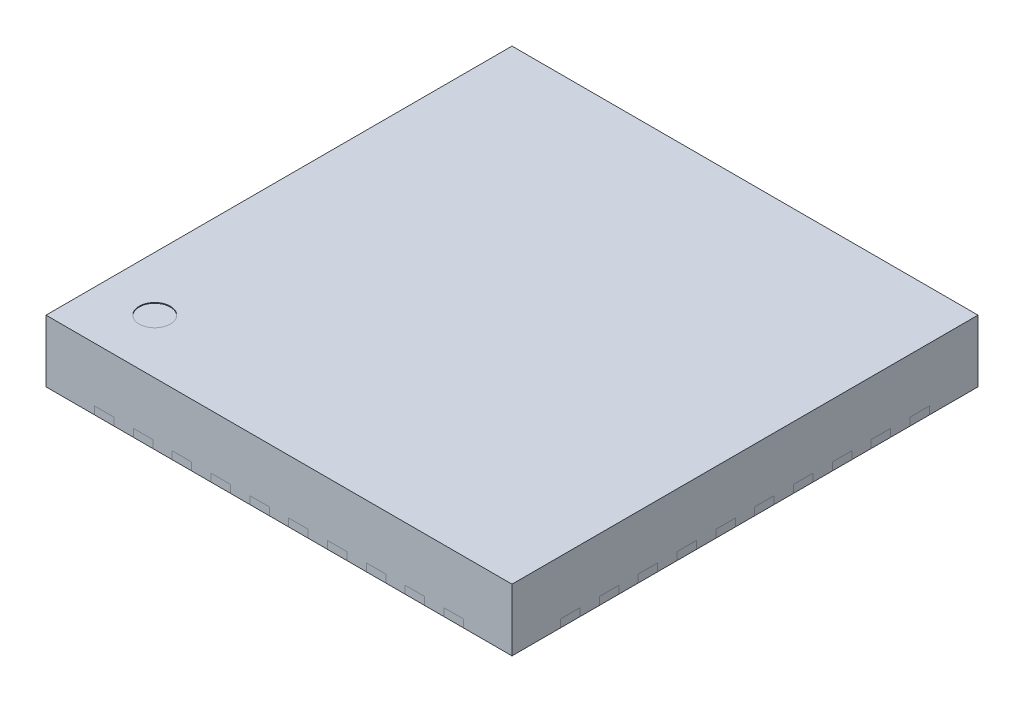
from build123d import *

# Parameters (mm, degrees)
SKETCH_1_W          = 6
SKETCH_1_H          = 6
EXTRUDE_1_DEPTH     = 0.8
SKETCH_2_W          = 0.25
SKETCH_2_H          = 0.4
SKETCH_2_W_2        = 0.4
SKETCH_2_H_2        = 0.25
CUT_EXTRUDE_2_DEPTH = 0.1
SKETCH_2_3_W        = 0.25
SKETCH_2_3_H        = 0.4
EXTRUDE_3_DEPTH     = 0.1
EXTRUDE_3_2_DEPTH   = 0.1
EXTRUDE_3_3_DEPTH   = 0.1
EXTRUDE_3_4_DEPTH   = 0.1
EXTRUDE_3_5_DEPTH   = 0.1
SKETCH_2_3_W_2      = 0.4
SKETCH_2_3_H_2      = 0.25
EXTRUDE_3_6_DEPTH   = 0.1
EXTRUDE_3_7_DEPTH   = 0.1
EXTRUDE_3_8_DEPTH   = 0.1
EXTRUDE_3_9_DEPTH   = 0.1
EXTRUDE_3_10_DEPTH  = 0.1
EXTRUDE_3_11_DEPTH  = 0.1
EXTRUDE_3_12_DEPTH  = 0.1
EXTRUDE_3_13_DEPTH  = 0.1
EXTRUDE_3_14_DEPTH  = 0.1
EXTRUDE_3_15_DEPTH  = 0.1
EXTRUDE_3_16_DEPTH  = 0.1
EXTRUDE_3_17_DEPTH  = 0.1
EXTRUDE_3_18_DEPTH  = 0.1
EXTRUDE_3_19_DEPTH  = 0.1
EXTRUDE_3_20_DEPTH  = 0.1
EXTRUDE_3_21_DEPTH  = 0.1
EXTRUDE_3_22_DEPTH  = 0.1
EXTRUDE_3_23_DEPTH  = 0.1
EXTRUDE_3_24_DEPTH  = 0.1
EXTRUDE_3_25_DEPTH  = 0.1
EXTRUDE_3_26_DEPTH  = 0.1
EXTRUDE_3_27_DEPTH  = 0.1
EXTRUDE_3_28_DEPTH  = 0.1
EXTRUDE_3_29_DEPTH  = 0.1
EXTRUDE_3_30_DEPTH  = 0.1
EXTRUDE_3_31_DEPTH  = 0.1
EXTRUDE_3_32_DEPTH  = 0.1
EXTRUDE_3_33_DEPTH  = 0.1
EXTRUDE_3_34_DEPTH  = 0.1
EXTRUDE_3_35_DEPTH  = 0.1
EXTRUDE_3_36_DEPTH  = 0.1
EXTRUDE_3_37_DEPTH  = 0.1
EXTRUDE_3_38_DEPTH  = 0.1
EXTRUDE_3_39_DEPTH  = 0.1
EXTRUDE_3_40_DEPTH  = 0.1
EXTRUDE_3_41_DEPTH  = 0.1
SKETCH_3_R          = 0.2
CUT_EXTRUDE_4_DEPTH = 0.01


with BuildPart() as part:
    # Эскиз1 → Вытянуть1 (new body)
    with BuildSketch(Plane(origin=(0, 0, 0), x_dir=(1, 0, 0), z_dir=(0, 1, 0))):
        Rectangle(SKETCH_1_W, SKETCH_1_H)
    extrude(amount=EXTRUDE_1_DEPTH)

    # Эскиз2 → Вытянуть2 (cut)
    with BuildSketch(Plane.XZ):
        with Locations((-0.25, 2.8)):
            Rectangle(SKETCH_2_W, SKETCH_2_H)
        with Locations((-0.75, 2.8)):
            Rectangle(SKETCH_2_W, SKETCH_2_H)
        with Locations((-1.25, 2.8)):
            Rectangle(SKETCH_2_W, SKETCH_2_H)
        with Locations((-1.75, 2.8)):
            Rectangle(SKETCH_2_W, SKETCH_2_H)
        with Locations((-2.25, 2.8)):
            Rectangle(SKETCH_2_W, SKETCH_2_H)
        with Locations((2.8, 0.25)):
            Rectangle(SKETCH_2_W_2, SKETCH_2_H_2)
        Polygon((-2.3, 2.05), (-2.05, 2.3), (2.3, 2.3), (2.3, -2.3), (-2.3, -2.3), align=None)
        with Locations((2.25, 2.8)):
            Rectangle(SKETCH_2_W, SKETCH_2_H)
        with Locations((1.75, 2.8)):
            Rectangle(SKETCH_2_W, SKETCH_2_H)
        with Locations((1.25, 2.8)):
            Rectangle(SKETCH_2_W, SKETCH_2_H)
        with Locations((0.75, 2.8)):
            Rectangle(SKETCH_2_W, SKETCH_2_H)
        with Locations((0.25, 2.8)):
            Rectangle(SKETCH_2_W, SKETCH_2_H)
        with Locations((2.8, 0.75)):
            Rectangle(SKETCH_2_W_2, SKETCH_2_H_2)
        with Locations((2.8, 1.25)):
            Rectangle(SKETCH_2_W_2, SKETCH_2_H_2)
        with Locations((2.8, 1.75)):
            Rectangle(SKETCH_2_W_2, SKETCH_2_H_2)
        with Locations((2.8, 2.25)):
            Rectangle(SKETCH_2_W_2, SKETCH_2_H_2)
        with Locations((2.8, -2.25)):
            Rectangle(SKETCH_2_W_2, SKETCH_2_H_2)
        with Locations((2.8, -1.75)):
            Rectangle(SKETCH_2_W_2, SKETCH_2_H_2)
        with Locations((2.8, -1.25)):
            Rectangle(SKETCH_2_W_2, SKETCH_2_H_2)
        with Locations((2.8, -0.75)):
            Rectangle(SKETCH_2_W_2, SKETCH_2_H_2)
        with Locations((2.8, -0.25)):
            Rectangle(SKETCH_2_W_2, SKETCH_2_H_2)
        with Locations((0.25, -2.8)):
            Rectangle(SKETCH_2_W, SKETCH_2_H)
        with Locations((0.75, -2.8)):
            Rectangle(SKETCH_2_W, SKETCH_2_H)
        with Locations((1.25, -2.8)):
            Rectangle(SKETCH_2_W, SKETCH_2_H)
        with Locations((1.75, -2.8)):
            Rectangle(SKETCH_2_W, SKETCH_2_H)
        with Locations((2.25, -2.8)):
            Rectangle(SKETCH_2_W, SKETCH_2_H)
        with Locations((-2.25, -2.8)):
            Rectangle(SKETCH_2_W, SKETCH_2_H)
        with Locations((-1.75, -2.8)):
            Rectangle(SKETCH_2_W, SKETCH_2_H)
        with Locations((-1.25, -2.8)):
            Rectangle(SKETCH_2_W, SKETCH_2_H)
        with Locations((-0.75, -2.8)):
            Rectangle(SKETCH_2_W, SKETCH_2_H)
        with Locations((-0.25, -2.8)):
            Rectangle(SKETCH_2_W, SKETCH_2_H)
        with Locations((-2.8, -0.25)):
            Rectangle(SKETCH_2_W_2, SKETCH_2_H_2)
        with Locations((-2.8, -0.75)):
            Rectangle(SKETCH_2_W_2, SKETCH_2_H_2)
        with Locations((-2.8, -1.25)):
            Rectangle(SKETCH_2_W_2, SKETCH_2_H_2)
        with Locations((-2.8, -1.75)):
            Rectangle(SKETCH_2_W_2, SKETCH_2_H_2)
        with Locations((-2.8, -2.25)):
            Rectangle(SKETCH_2_W_2, SKETCH_2_H_2)
        with Locations((-2.8, 2.25)):
            Rectangle(SKETCH_2_W_2, SKETCH_2_H_2)
        with Locations((-2.8, 1.75)):
            Rectangle(SKETCH_2_W_2, SKETCH_2_H_2)
        with Locations((-2.8, 1.25)):
            Rectangle(SKETCH_2_W_2, SKETCH_2_H_2)
        with Locations((-2.8, 0.75)):
            Rectangle(SKETCH_2_W_2, SKETCH_2_H_2)
        with Locations((-2.8, 0.25)):
            Rectangle(SKETCH_2_W_2, SKETCH_2_H_2)
    extrude(amount=-CUT_EXTRUDE_2_DEPTH, mode=Mode.SUBTRACT)

    # Эскиз3 → Вытянуть4 (cut)
    with BuildSketch(Plane(origin=(0, 0.8, 0), x_dir=(1, 0, 0), z_dir=(0, 1, 0))):
        with Locations((-2.3, -2.3)):
            Circle(SKETCH_3_R)
    extrude(amount=-CUT_EXTRUDE_4_DEPTH, mode=Mode.SUBTRACT)


with BuildPart() as body_2:
    # Эскиз2<3> → Вытянуть3 (new body)
    with BuildSketch(Plane.XZ):
        with Locations((-0.25, 2.8)):
            Rectangle(SKETCH_2_3_W, SKETCH_2_3_H)
    extrude(amount=-EXTRUDE_3_DEPTH)


with BuildPart() as body_3:
    # Эскиз2<3> → Extrude 3 2 (new body)
    with BuildSketch(Plane.XZ):
        with Locations((-0.75, 2.8)):
            Rectangle(SKETCH_2_3_W, SKETCH_2_3_H)
    extrude(amount=-EXTRUDE_3_2_DEPTH)


with BuildPart() as body_4:
    # Эскиз2<3> → Extrude 3 3 (new body)
    with BuildSketch(Plane.XZ):
        with Locations((-1.25, 2.8)):
            Rectangle(SKETCH_2_3_W, SKETCH_2_3_H)
    extrude(amount=-EXTRUDE_3_3_DEPTH)


with BuildPart() as body_5:
    # Эскиз2<3> → Extrude 3 4 (new body)
    with BuildSketch(Plane.XZ):
        with Locations((-1.75, 2.8)):
            Rectangle(SKETCH_2_3_W, SKETCH_2_3_H)
    extrude(amount=-EXTRUDE_3_4_DEPTH)


with BuildPart() as body_6:
    # Эскиз2<3> → Extrude 3 5 (new body)
    with BuildSketch(Plane.XZ):
        with Locations((-2.25, 2.8)):
            Rectangle(SKETCH_2_3_W, SKETCH_2_3_H)
    extrude(amount=-EXTRUDE_3_5_DEPTH)


with BuildPart() as body_7:
    # Эскиз2<3> → Extrude 3 6 (new body)
    with BuildSketch(Plane.XZ):
        with Locations((2.8, 0.25)):
            Rectangle(SKETCH_2_3_W_2, SKETCH_2_3_H_2)
    extrude(amount=-EXTRUDE_3_6_DEPTH)


with BuildPart() as body_8:
    # Эскиз2<3> → Extrude 3 7 (new body)
    with BuildSketch(Plane.XZ):
        Polygon((-2.3, 2.05), (-2.05, 2.3), (2.3, 2.3), (2.3, -2.3), (-2.3, -2.3), align=None)
    extrude(amount=-EXTRUDE_3_7_DEPTH)


with BuildPart() as body_9:
    # Эскиз2<3> → Extrude 3 8 (new body)
    with BuildSketch(Plane.XZ):
        with Locations((2.25, 2.8)):
            Rectangle(SKETCH_2_3_W, SKETCH_2_3_H)
    extrude(amount=-EXTRUDE_3_8_DEPTH)


with BuildPart() as body_10:
    # Эскиз2<3> → Extrude 3 9 (new body)
    with BuildSketch(Plane.XZ):
        with Locations((1.75, 2.8)):
            Rectangle(SKETCH_2_3_W, SKETCH_2_3_H)
    extrude(amount=-EXTRUDE_3_9_DEPTH)


with BuildPart() as body_11:
    # Эскиз2<3> → Extrude 3 10 (new body)
    with BuildSketch(Plane.XZ):
        with Locations((1.25, 2.8)):
            Rectangle(SKETCH_2_3_W, SKETCH_2_3_H)
    extrude(amount=-EXTRUDE_3_10_DEPTH)


with BuildPart() as body_12:
    # Эскиз2<3> → Extrude 3 11 (new body)
    with BuildSketch(Plane.XZ):
        with Locations((0.75, 2.8)):
            Rectangle(SKETCH_2_3_W, SKETCH_2_3_H)
    extrude(amount=-EXTRUDE_3_11_DEPTH)


with BuildPart() as body_13:
    # Эскиз2<3> → Extrude 3 12 (new body)
    with BuildSketch(Plane.XZ):
        with Locations((0.25, 2.8)):
            Rectangle(SKETCH_2_3_W, SKETCH_2_3_H)
    extrude(amount=-EXTRUDE_3_12_DEPTH)


with BuildPart() as body_14:
    # Эскиз2<3> → Extrude 3 13 (new body)
    with BuildSketch(Plane.XZ):
        with Locations((2.8, 0.75)):
            Rectangle(SKETCH_2_3_W_2, SKETCH_2_3_H_2)
    extrude(amount=-EXTRUDE_3_13_DEPTH)


with BuildPart() as body_15:
    # Эскиз2<3> → Extrude 3 14 (new body)
    with BuildSketch(Plane.XZ):
        with Locations((2.8, 1.25)):
            Rectangle(SKETCH_2_3_W_2, SKETCH_2_3_H_2)
    extrude(amount=-EXTRUDE_3_14_DEPTH)


with BuildPart() as body_16:
    # Эскиз2<3> → Extrude 3 15 (new body)
    with BuildSketch(Plane.XZ):
        with Locations((2.8, 1.75)):
            Rectangle(SKETCH_2_3_W_2, SKETCH_2_3_H_2)
    extrude(amount=-EXTRUDE_3_15_DEPTH)


with BuildPart() as body_17:
    # Эскиз2<3> → Extrude 3 16 (new body)
    with BuildSketch(Plane.XZ):
        with Locations((2.8, 2.25)):
            Rectangle(SKETCH_2_3_W_2, SKETCH_2_3_H_2)
    extrude(amount=-EXTRUDE_3_16_DEPTH)


with BuildPart() as body_18:
    # Эскиз2<3> → Extrude 3 17 (new body)
    with BuildSketch(Plane.XZ):
        with Locations((2.8, -2.25)):
            Rectangle(SKETCH_2_3_W_2, SKETCH_2_3_H_2)
    extrude(amount=-EXTRUDE_3_17_DEPTH)


with BuildPart() as body_19:
    # Эскиз2<3> → Extrude 3 18 (new body)
    with BuildSketch(Plane.XZ):
        with Locations((2.8, -1.75)):
            Rectangle(SKETCH_2_3_W_2, SKETCH_2_3_H_2)
    extrude(amount=-EXTRUDE_3_18_DEPTH)


with BuildPart() as body_20:
    # Эскиз2<3> → Extrude 3 19 (new body)
    with BuildSketch(Plane.XZ):
        with Locations((2.8, -1.25)):
            Rectangle(SKETCH_2_3_W_2, SKETCH_2_3_H_2)
    extrude(amount=-EXTRUDE_3_19_DEPTH)


with BuildPart() as body_21:
    # Эскиз2<3> → Extrude 3 20 (new body)
    with BuildSketch(Plane.XZ):
        with Locations((2.8, -0.75)):
            Rectangle(SKETCH_2_3_W_2, SKETCH_2_3_H_2)
    extrude(amount=-EXTRUDE_3_20_DEPTH)


with BuildPart() as body_22:
    # Эскиз2<3> → Extrude 3 21 (new body)
    with BuildSketch(Plane.XZ):
        with Locations((2.8, -0.25)):
            Rectangle(SKETCH_2_3_W_2, SKETCH_2_3_H_2)
    extrude(amount=-EXTRUDE_3_21_DEPTH)


with BuildPart() as body_23:
    # Эскиз2<3> → Extrude 3 22 (new body)
    with BuildSketch(Plane.XZ):
        with Locations((0.25, -2.8)):
            Rectangle(SKETCH_2_3_W, SKETCH_2_3_H)
    extrude(amount=-EXTRUDE_3_22_DEPTH)


with BuildPart() as body_24:
    # Эскиз2<3> → Extrude 3 23 (new body)
    with BuildSketch(Plane.XZ):
        with Locations((0.75, -2.8)):
            Rectangle(SKETCH_2_3_W, SKETCH_2_3_H)
    extrude(amount=-EXTRUDE_3_23_DEPTH)


with BuildPart() as body_25:
    # Эскиз2<3> → Extrude 3 24 (new body)
    with BuildSketch(Plane.XZ):
        with Locations((1.25, -2.8)):
            Rectangle(SKETCH_2_3_W, SKETCH_2_3_H)
    extrude(amount=-EXTRUDE_3_24_DEPTH)


with BuildPart() as body_26:
    # Эскиз2<3> → Extrude 3 25 (new body)
    with BuildSketch(Plane.XZ):
        with Locations((1.75, -2.8)):
            Rectangle(SKETCH_2_3_W, SKETCH_2_3_H)
    extrude(amount=-EXTRUDE_3_25_DEPTH)


with BuildPart() as body_27:
    # Эскиз2<3> → Extrude 3 26 (new body)
    with BuildSketch(Plane.XZ):
        with Locations((2.25, -2.8)):
            Rectangle(SKETCH_2_3_W, SKETCH_2_3_H)
    extrude(amount=-EXTRUDE_3_26_DEPTH)


with BuildPart() as body_28:
    # Эскиз2<3> → Extrude 3 27 (new body)
    with BuildSketch(Plane.XZ):
        with Locations((-2.25, -2.8)):
            Rectangle(SKETCH_2_3_W, SKETCH_2_3_H)
    extrude(amount=-EXTRUDE_3_27_DEPTH)


with BuildPart() as body_29:
    # Эскиз2<3> → Extrude 3 28 (new body)
    with BuildSketch(Plane.XZ):
        with Locations((-1.75, -2.8)):
            Rectangle(SKETCH_2_3_W, SKETCH_2_3_H)
    extrude(amount=-EXTRUDE_3_28_DEPTH)


with BuildPart() as body_30:
    # Эскиз2<3> → Extrude 3 29 (new body)
    with BuildSketch(Plane.XZ):
        with Locations((-1.25, -2.8)):
            Rectangle(SKETCH_2_3_W, SKETCH_2_3_H)
    extrude(amount=-EXTRUDE_3_29_DEPTH)


with BuildPart() as body_31:
    # Эскиз2<3> → Extrude 3 30 (new body)
    with BuildSketch(Plane.XZ):
        with Locations((-0.75, -2.8)):
            Rectangle(SKETCH_2_3_W, SKETCH_2_3_H)
    extrude(amount=-EXTRUDE_3_30_DEPTH)


with BuildPart() as body_32:
    # Эскиз2<3> → Extrude 3 31 (new body)
    with BuildSketch(Plane.XZ):
        with Locations((-0.25, -2.8)):
            Rectangle(SKETCH_2_3_W, SKETCH_2_3_H)
    extrude(amount=-EXTRUDE_3_31_DEPTH)


with BuildPart() as body_33:
    # Эскиз2<3> → Extrude 3 32 (new body)
    with BuildSketch(Plane.XZ):
        with Locations((-2.8, -0.25)):
            Rectangle(SKETCH_2_3_W_2, SKETCH_2_3_H_2)
    extrude(amount=-EXTRUDE_3_32_DEPTH)


with BuildPart() as body_34:
    # Эскиз2<3> → Extrude 3 33 (new body)
    with BuildSketch(Plane.XZ):
        with Locations((-2.8, -0.75)):
            Rectangle(SKETCH_2_3_W_2, SKETCH_2_3_H_2)
    extrude(amount=-EXTRUDE_3_33_DEPTH)


with BuildPart() as body_35:
    # Эскиз2<3> → Extrude 3 34 (new body)
    with BuildSketch(Plane.XZ):
        with Locations((-2.8, -1.25)):
            Rectangle(SKETCH_2_3_W_2, SKETCH_2_3_H_2)
    extrude(amount=-EXTRUDE_3_34_DEPTH)


with BuildPart() as body_36:
    # Эскиз2<3> → Extrude 3 35 (new body)
    with BuildSketch(Plane.XZ):
        with Locations((-2.8, -1.75)):
            Rectangle(SKETCH_2_3_W_2, SKETCH_2_3_H_2)
    extrude(amount=-EXTRUDE_3_35_DEPTH)


with BuildPart() as body_37:
    # Эскиз2<3> → Extrude 3 36 (new body)
    with BuildSketch(Plane.XZ):
        with Locations((-2.8, -2.25)):
            Rectangle(SKETCH_2_3_W_2, SKETCH_2_3_H_2)
    extrude(amount=-EXTRUDE_3_36_DEPTH)


with BuildPart() as body_38:
    # Эскиз2<3> → Extrude 3 37 (new body)
    with BuildSketch(Plane.XZ):
        with Locations((-2.8, 2.25)):
            Rectangle(SKETCH_2_3_W_2, SKETCH_2_3_H_2)
    extrude(amount=-EXTRUDE_3_37_DEPTH)


with BuildPart() as body_39:
    # Эскиз2<3> → Extrude 3 38 (new body)
    with BuildSketch(Plane.XZ):
        with Locations((-2.8, 1.75)):
            Rectangle(SKETCH_2_3_W_2, SKETCH_2_3_H_2)
    extrude(amount=-EXTRUDE_3_38_DEPTH)


with BuildPart() as body_40:
    # Эскиз2<3> → Extrude 3 39 (new body)
    with BuildSketch(Plane.XZ):
        with Locations((-2.8, 1.25)):
            Rectangle(SKETCH_2_3_W_2, SKETCH_2_3_H_2)
    extrude(amount=-EXTRUDE_3_39_DEPTH)


with BuildPart() as body_41:
    # Эскиз2<3> → Extrude 3 40 (new body)
    with BuildSketch(Plane.XZ):
        with Locations((-2.8, 0.75)):
            Rectangle(SKETCH_2_3_W_2, SKETCH_2_3_H_2)
    extrude(amount=-EXTRUDE_3_40_DEPTH)


with BuildPart() as body_42:
    # Эскиз2<3> → Extrude 3 41 (new body)
    with BuildSketch(Plane.XZ):
        with Locations((-2.8, 0.25)):
            Rectangle(SKETCH_2_3_W_2, SKETCH_2_3_H_2)
    extrude(amount=-EXTRUDE_3_41_DEPTH)


solid = Compound([part.part, body_2.part, body_3.part, body_4.part, body_5.part, body_6.part, body_7.part, body_8.part, body_9.part, body_10.part, body_11.part, body_12.part, body_13.part, body_14.part, body_15.part, body_16.part, body_17.part, body_18.part, body_19.part, body_20.part, body_21.part, body_22.part, body_23.part, body_24.part, body_25.part, body_26.part, body_27.part, body_28.part, body_29.part, body_30.part, body_31.part, body_32.part, body_33.part, body_34.part, body_35.part, body_36.part, body_37.part, body_38.part, body_39.part, body_40.part, body_41.part, body_42.part])
